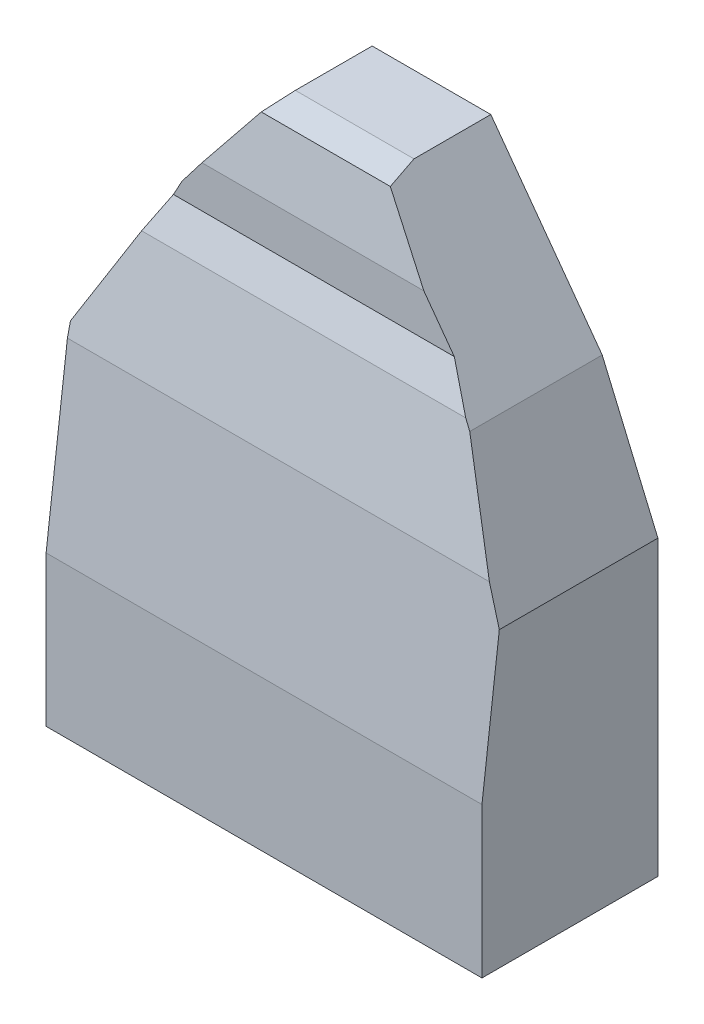
from build123d import *

# Parameters (mm, degrees)
BOSS_EXTRUDE1_DEPTH = 101.6
BOSS_EXTRUDE2_DEPTH = 576.302521
CUT_EXTRUDE1_DEPTH  = 132.021743181
CUT_EXTRUDE2_DEPTH  = 132.021743181


with BuildPart() as part:
    # Sketch1 → Boss-Extrude1 (new body)
    with BuildSketch(Plane.XY):
        Polygon((0, 0), (576.302521008, 0), (576.302521008, 387.403361345), (502.663865546, 560.294117647), (355.386554622, 762), (198.504201681, 762), (102.453781513, 637.134453782), (0, 448.235294118), align=None)
    extrude(amount=BOSS_EXTRUDE1_DEPTH)

    # Sketch2 → Boss-Extrude2 (add)
    with BuildSketch(Plane.ZY):
        Polygon((101.6, 0), (232.621743181, 0), (232.621743181, 198.64821401), (204.451845393, 430.506603568), (172.780455352, 570.81191653), (155.089264466, 615.704741573), (155.089264466, 670.908278379), (139.607943989, 752.787376516), (101.6, 762), align=None)
    extrude(amount=-BOSS_EXTRUDE2_DEPTH)

    # Sketch3 → Cut-Extrude1 (cut, through all)
    with BuildSketch(Plane(origin=(0, 0, 101.6), x_dir=(-1, 0, 0), z_dir=(0, 0, -1))):
        Polygon((0, 448.235294118), (-102.079559314, 636.444481603), (-205.052343037, 770.512583763), (-205.052343037, 987.342816442), (227.879484492, 941.92173413), (179.71587047, 482.849418415), align=None)
    extrude(amount=-CUT_EXTRUDE1_DEPTH, mode=Mode.SUBTRACT)

    # Sketch4 → Cut-Extrude2 (cut, through all)
    with BuildSketch(Plane(origin=(0, 0, 101.6), x_dir=(-1, 0, 0), z_dir=(0, 0, -1))):
        Polygon((-576.302521008, 387.403361345), (-502.663865546, 560.294117647), (-355.386554622, 762), (-386.647779508, 961.526140846), (-935.090979015, 961.526140846), (-884.913915701, 472.949119069), align=None)
    extrude(amount=-CUT_EXTRUDE2_DEPTH, mode=Mode.SUBTRACT)


solid = part.part
